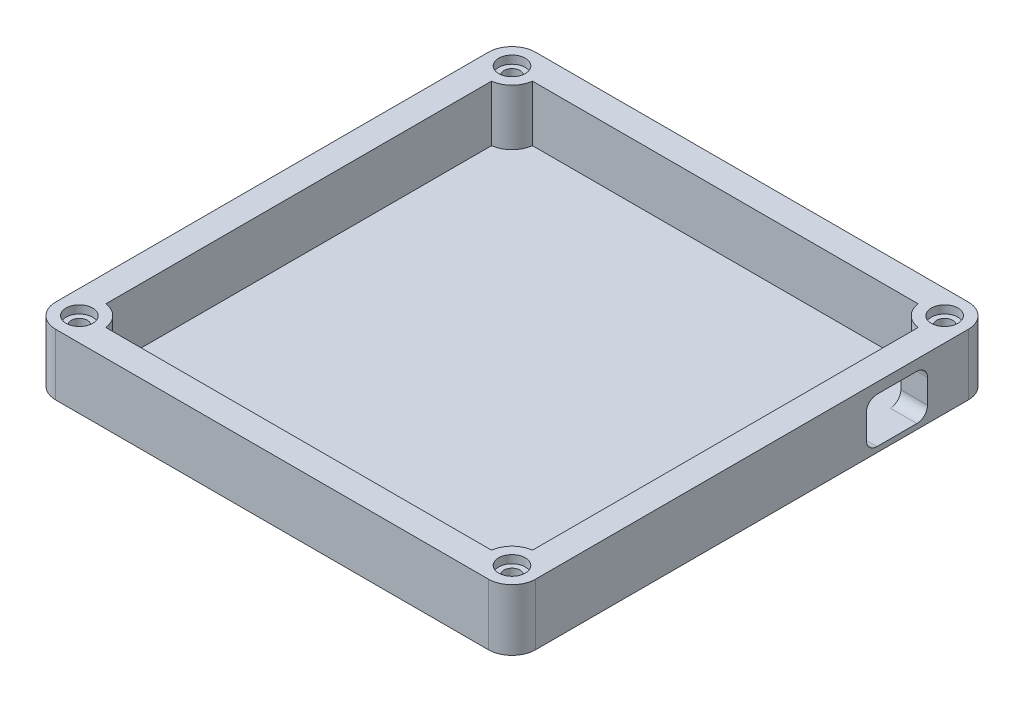
from build123d import *

# Parameters (mm, degrees)
SKETCH1_W           = 7.937979337
SKETCH1_H           = 0.559115352
BOSS_EXTRUDE1_DEPTH = 11.5
SKETCH2_R           = 1.5
CUT_EXTRUDE1_DEPTH  = 8
CUT_EXTRUDE2_DEPTH  = 8
SKETCH4_R           = 2.5
CUT_EXTRUDE3_DEPTH  = 1.5
BOSS_EXTRUDE2_DEPTH = 1


with BuildPart() as part:
    # Sketch1 → Boss-Extrude1 (new body)
    with BuildSketch(Plane(origin=(0, 0, 0), x_dir=(1, 0, 0), z_dir=(0, 1, 0))):
        with BuildLine():
            Line((-40.080884648, -36.23445276), (-40.080884648, 18.423402639))
            Line((-40.080884648, 18.423402639), (-40.64, 18.423402639))
            Line((-40.64, 18.423402639), (-40.64, -36.199115352))
            ThreePointArc((-40.64, -36.199115352), (-40.359884529, -36.207958509), (-40.080884648, -36.23445276))
        make_face()
        with BuildLine():
            Line((-40.080884648, 18.423402639), (-40.080884648, 36.23445276))
            ThreePointArc((-40.080884648, 36.23445276), (-40.359884529, 36.207958509), (-40.64, 36.199115352))
            Line((-40.64, 36.199115352), (-40.64, 18.423402639))
            Line((-40.64, 18.423402639), (-40.080884648, 18.423402639))
        make_face()
        with BuildLine():
            Line((-36.23445276, 40.080884648), (-7.937979337, 40.080884648))
            Line((-7.937979337, 40.080884648), (-7.937979337, 40.64))
            Line((-7.937979337, 40.64), (-36.199115352, 40.64))
            ThreePointArc((-36.199115352, 40.64), (-36.207958509, 40.359884529), (-36.23445276, 40.080884648))
        make_face()
        with BuildLine():
            Line((0, 40.64), (0, 40.080884648))
            Line((0, 40.080884648), (36.23445276, 40.080884648))
            ThreePointArc((36.23445276, 40.080884648), (36.207958509, 40.359884529), (36.199115352, 40.64))
            Line((36.199115352, 40.64), (0, 40.64))
        make_face()
        with Locations((-3.968989669, 40.360442324)):
            Rectangle(SKETCH1_W, SKETCH1_H)
        with BuildLine():
            ThreePointArc((40.64, 36.199115352), (40.359884529, 36.207958509), (40.080884648, 36.23445276))
            Line((40.080884648, 36.23445276), (40.080884648, 28.268480093))
            Line((40.080884648, 28.268480093), (40.64, 28.268480093))
            Line((40.64, 28.268480093), (40.64, 36.199115352))
        make_face()
        with BuildLine():
            Line((40.64, 28.268480093), (40.080884648, 28.268480093))
            Line((40.080884648, 28.268480093), (40.080884648, -36.23445276))
            ThreePointArc((40.080884648, -36.23445276), (40.359884529, -36.207958509), (40.64, -36.199115352))
            Line((40.64, -36.199115352), (40.64, 28.268480093))
        make_face()
        with BuildLine():
            ThreePointArc((40.64, -36.199115352), (40.359884529, -36.207958509), (40.080884648, -36.23445276))
            ThreePointArc((40.080884648, -36.23445276), (37.499820351, -37.499820351), (36.23445276, -40.080884648))
            ThreePointArc((36.23445276, -40.080884648), (36.207958509, -40.359884529), (36.199115352, -40.64))
            Line((36.199115352, -40.64), (40.64, -40.64))
            Line((40.64, -40.64), (40.64, -36.199115352))
        make_face()
        with BuildLine():
            ThreePointArc((45.080884648, -40.64), (43.780179649, -37.499820351), (40.64, -36.199115352))
            Line((40.64, -36.199115352), (40.64, -40.64))
            Line((40.64, -40.64), (36.199115352, -40.64))
            ThreePointArc((36.199115352, -40.64), (37.499820351, -43.780179649), (40.64, -45.080884648))
            ThreePointArc((40.64, -45.080884648), (43.780179649, -43.780179649), (45.080884648, -40.64))
        make_face()
        with BuildLine():
            ThreePointArc((36.199115352, -40.64), (36.207958509, -40.359884529), (36.23445276, -40.080884648))
            Line((36.23445276, -40.080884648), (27.085817246, -40.080884648))
            Line((27.085817246, -40.080884648), (27.085817246, -40.64))
            Line((27.085817246, -40.64), (36.199115352, -40.64))
        make_face()
        with BuildLine():
            Line((27.085817246, -40.080884648), (-36.23445276, -40.080884648))
            ThreePointArc((-36.23445276, -40.080884648), (-36.207958509, -40.359884529), (-36.199115352, -40.64))
            Line((-36.199115352, -40.64), (27.085817246, -40.64))
            Line((27.085817246, -40.64), (27.085817246, -40.080884648))
        make_face()
        with BuildLine():
            Line((-40.64, -40.64), (-40.64, -36.199115352))
            ThreePointArc((-40.64, -36.199115352), (-43.780179649, -37.499820351), (-45.080884648, -40.64))
            ThreePointArc((-45.080884648, -40.64), (-43.780179649, -43.780179649), (-40.64, -45.080884648))
            ThreePointArc((-40.64, -45.080884648), (-37.499820351, -43.780179649), (-36.199115352, -40.64))
            Line((-36.199115352, -40.64), (-40.64, -40.64))
        make_face()
        with BuildLine():
            ThreePointArc((-36.23445276, -40.080884648), (-37.499820351, -37.499820351), (-40.080884648, -36.23445276))
            ThreePointArc((-40.080884648, -36.23445276), (-40.359884529, -36.207958509), (-40.64, -36.199115352))
            Line((-40.64, -36.199115352), (-40.64, -40.64))
            Line((-40.64, -40.64), (-36.199115352, -40.64))
            ThreePointArc((-36.199115352, -40.64), (-36.207958509, -40.359884529), (-36.23445276, -40.080884648))
        make_face()
        with BuildLine():
            Line((-40.64, -40.64), (-40.64, -36.199115352))
            ThreePointArc((-40.64, -36.199115352), (-43.780179649, -37.499820351), (-45.080884648, -40.64))
            ThreePointArc((-45.080884648, -40.64), (-43.780179649, -43.780179649), (-40.64, -45.080884648))
            ThreePointArc((-40.64, -45.080884648), (-37.499820351, -43.780179649), (-36.199115352, -40.64))
            Line((-36.199115352, -40.64), (-40.64, -40.64))
        make_face()
        with BuildLine():
            Line((27.085817246, -40.64), (-36.199115352, -40.64))
            ThreePointArc((-36.199115352, -40.64), (-37.499820351, -43.780179649), (-40.64, -45.080884648))
            Line((-40.64, -45.080884648), (27.085817246, -45.080884648))
            Line((27.085817246, -45.080884648), (27.085817246, -40.64))
        make_face()
        with BuildLine():
            Line((-40.64, -36.199115352), (-40.64, 18.423402639))
            Line((-40.64, 18.423402639), (-45.080884648, 18.423402639))
            Line((-45.080884648, 18.423402639), (-45.080884648, -40.64))
            ThreePointArc((-45.080884648, -40.64), (-43.780179649, -37.499820351), (-40.64, -36.199115352))
        make_face()
        with BuildLine():
            ThreePointArc((45.080884648, -40.64), (43.780179649, -37.499820351), (40.64, -36.199115352))
            Line((40.64, -36.199115352), (40.64, -40.64))
            Line((40.64, -40.64), (36.199115352, -40.64))
            ThreePointArc((36.199115352, -40.64), (37.499820351, -43.780179649), (40.64, -45.080884648))
            ThreePointArc((40.64, -45.080884648), (43.780179649, -43.780179649), (45.080884648, -40.64))
        make_face()
        with BuildLine():
            ThreePointArc((40.64, -45.080884648), (37.499820351, -43.780179649), (36.199115352, -40.64))
            Line((36.199115352, -40.64), (27.085817246, -40.64))
            Line((27.085817246, -40.64), (27.085817246, -45.080884648))
            Line((27.085817246, -45.080884648), (40.64, -45.080884648))
        make_face()
        with BuildLine():
            Line((45.080884648, 28.268480093), (40.64, 28.268480093))
            Line((40.64, 28.268480093), (40.64, -36.199115352))
            ThreePointArc((40.64, -36.199115352), (43.780179649, -37.499820351), (45.080884648, -40.64))
            Line((45.080884648, -40.64), (45.080884648, 28.268480093))
        make_face()
        with BuildLine():
            ThreePointArc((45.080884648, 40.64), (43.780179649, 37.499820351), (40.64, 36.199115352))
            Line((40.64, 36.199115352), (40.64, 28.268480093))
            Line((40.64, 28.268480093), (45.080884648, 28.268480093))
            Line((45.080884648, 28.268480093), (45.080884648, 40.64))
        make_face()
        with BuildLine():
            ThreePointArc((40.64, 45.080884648), (37.499820351, 43.780179649), (36.199115352, 40.64))
            Line((36.199115352, 40.64), (40.64, 40.64))
            Line((40.64, 40.64), (40.64, 36.199115352))
            ThreePointArc((40.64, 36.199115352), (43.780179649, 37.499820351), (45.080884648, 40.64))
            ThreePointArc((45.080884648, 40.64), (43.780179649, 43.780179649), (40.64, 45.080884648))
        make_face()
        with BuildLine():
            ThreePointArc((36.199115352, 40.64), (36.207958509, 40.359884529), (36.23445276, 40.080884648))
            ThreePointArc((36.23445276, 40.080884648), (37.499820351, 37.499820351), (40.080884648, 36.23445276))
            ThreePointArc((40.080884648, 36.23445276), (40.359884529, 36.207958509), (40.64, 36.199115352))
            Line((40.64, 36.199115352), (40.64, 40.64))
            Line((40.64, 40.64), (36.199115352, 40.64))
        make_face()
        with BuildLine():
            ThreePointArc((40.64, 45.080884648), (37.499820351, 43.780179649), (36.199115352, 40.64))
            Line((36.199115352, 40.64), (40.64, 40.64))
            Line((40.64, 40.64), (40.64, 36.199115352))
            ThreePointArc((40.64, 36.199115352), (43.780179649, 37.499820351), (45.080884648, 40.64))
            ThreePointArc((45.080884648, 40.64), (43.780179649, 43.780179649), (40.64, 45.080884648))
        make_face()
        with BuildLine():
            Line((-7.937979337, 40.64), (0, 40.64))
            Line((0, 40.64), (36.199115352, 40.64))
            ThreePointArc((36.199115352, 40.64), (37.499820351, 43.780179649), (40.64, 45.080884648))
            Line((40.64, 45.080884648), (-7.937979337, 45.080884648))
            Line((-7.937979337, 45.080884648), (-7.937979337, 40.64))
        make_face()
        with BuildLine():
            Line((-36.199115352, 40.64), (-7.937979337, 40.64))
            Line((-7.937979337, 40.64), (-7.937979337, 45.080884648))
            Line((-7.937979337, 45.080884648), (-40.64, 45.080884648))
            ThreePointArc((-40.64, 45.080884648), (-37.499820351, 43.780179649), (-36.199115352, 40.64))
        make_face()
        with BuildLine():
            Line((-40.64, 40.64), (-36.199115352, 40.64))
            ThreePointArc((-36.199115352, 40.64), (-37.499820351, 43.780179649), (-40.64, 45.080884648))
            ThreePointArc((-40.64, 45.080884648), (-43.780179649, 43.780179649), (-45.080884648, 40.64))
            ThreePointArc((-45.080884648, 40.64), (-43.780179649, 37.499820351), (-40.64, 36.199115352))
            Line((-40.64, 36.199115352), (-40.64, 40.64))
        make_face()
        with BuildLine():
            ThreePointArc((-40.080884648, 36.23445276), (-37.499820351, 37.499820351), (-36.23445276, 40.080884648))
            ThreePointArc((-36.23445276, 40.080884648), (-36.207958509, 40.359884529), (-36.199115352, 40.64))
            Line((-36.199115352, 40.64), (-40.64, 40.64))
            Line((-40.64, 40.64), (-40.64, 36.199115352))
            ThreePointArc((-40.64, 36.199115352), (-40.359884529, 36.207958509), (-40.080884648, 36.23445276))
        make_face()
        with BuildLine():
            Line((-40.64, 40.64), (-36.199115352, 40.64))
            ThreePointArc((-36.199115352, 40.64), (-37.499820351, 43.780179649), (-40.64, 45.080884648))
            ThreePointArc((-40.64, 45.080884648), (-43.780179649, 43.780179649), (-45.080884648, 40.64))
            ThreePointArc((-45.080884648, 40.64), (-43.780179649, 37.499820351), (-40.64, 36.199115352))
            Line((-40.64, 36.199115352), (-40.64, 40.64))
        make_face()
        with BuildLine():
            Line((-40.64, 18.423402639), (-40.64, 36.199115352))
            ThreePointArc((-40.64, 36.199115352), (-43.780179649, 37.499820351), (-45.080884648, 40.64))
            Line((-45.080884648, 40.64), (-45.080884648, 18.423402639))
            Line((-45.080884648, 18.423402639), (-40.64, 18.423402639))
        make_face()
    extrude(amount=BOSS_EXTRUDE1_DEPTH)

    # Sketch2 → Cut-Extrude1 (cut)
    with BuildSketch(Plane(origin=(0, 11.5, 0), x_dir=(1, 0, 0), z_dir=(0, 1, 0))):
        with Locations((-40.64, 40.64)):
            Circle(SKETCH2_R)
        with Locations((40.64, 40.64)):
            Circle(SKETCH2_R)
        with Locations((40.64, -40.64)):
            Circle(SKETCH2_R)
        with Locations((-40.64, -40.64)):
            Circle(SKETCH2_R)
    extrude(amount=-CUT_EXTRUDE1_DEPTH, mode=Mode.SUBTRACT)

    # Sketch3 → Cut-Extrude2 (cut)
    with BuildSketch(Plane(origin=(45.080884648, 0, 0), x_dir=(0, 0, -1), z_dir=(1, 0, 0))):
        with BuildLine():
            Line((30.979, 9.5), (23.479, 9.5))
            ThreePointArc((23.479, 9.5), (22.064786438, 8.914213562), (21.479, 7.5))
            Line((21.479, 7.5), (21.479, 3))
            ThreePointArc((21.479, 3), (22.064786438, 1.585786438), (23.479, 1))
            Line((23.479, 1), (30.979, 1))
            ThreePointArc((30.979, 1), (32.393213562, 1.585786438), (32.979, 3))
            Line((32.979, 3), (32.979, 7.5))
            ThreePointArc((32.979, 7.5), (32.393213562, 8.914213562), (30.979, 9.5))
        make_face()
    extrude(amount=-CUT_EXTRUDE2_DEPTH, mode=Mode.SUBTRACT)

    # Sketch4 → Cut-Extrude3 (cut)
    with BuildSketch(Plane(origin=(0, 11.5, 0), x_dir=(1, 0, 0), z_dir=(0, 1, 0))):
        with Locations((-40.64, 40.64)):
            Circle(SKETCH4_R)
        with Locations((40.64, 40.64)):
            Circle(SKETCH4_R)
        with Locations((40.64, -40.64)):
            Circle(SKETCH4_R)
        with Locations((-40.64, -40.64)):
            Circle(SKETCH4_R)
    extrude(amount=-CUT_EXTRUDE3_DEPTH, mode=Mode.SUBTRACT)

    # Sketch5 → Boss-Extrude2 (add)
    with BuildSketch(Plane.XZ):
        with BuildLine():
            ThreePointArc((36.23445276, 40.080884648), (37.499820351, 37.499820351), (40.080884648, 36.23445276))
            Line((40.080884648, 36.23445276), (40.080884648, -36.23445276))
            ThreePointArc((40.080884648, -36.23445276), (37.499820351, -37.499820351), (36.23445276, -40.080884648))
            Line((36.23445276, -40.080884648), (-36.23445276, -40.080884648))
            ThreePointArc((-36.23445276, -40.080884648), (-37.499820351, -37.499820351), (-40.080884648, -36.23445276))
            Line((-40.080884648, -36.23445276), (-40.080884648, 36.23445276))
            ThreePointArc((-40.080884648, 36.23445276), (-37.499820351, 37.499820351), (-36.23445276, 40.080884648))
            Line((-36.23445276, 40.080884648), (36.23445276, 40.080884648))
        make_face()
    extrude(amount=-BOSS_EXTRUDE2_DEPTH)


solid = part.part
